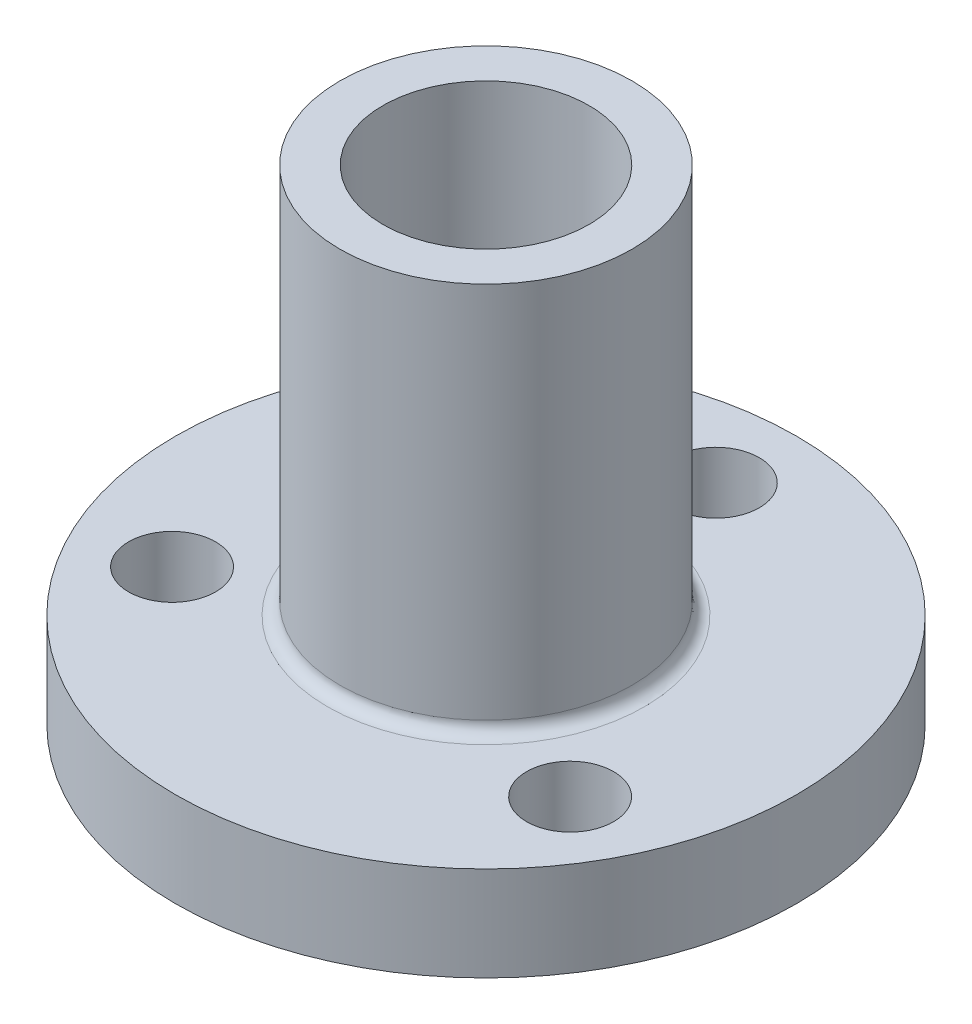
from build123d import *

# Parameters (mm, degrees)
ESBO_O1_R                = 12.5
ESBO_O1_R_2              = 1.75
ESBO_O1_R_3              = 5.875
RESSALTO_EXTRUS_O1_DEPTH = 3.8
ESBO_O1_3_R              = 5.875
ESBO_O1_3_R_2            = 4.15
RESSALTO_EXTRUS_O2_DEPTH = 19.5
FILETE1_R                = 0.5


with BuildPart() as part:
    # Esboço1 → Ressalto-extrusão1 (new body)
    with BuildSketch(Plane(origin=(0, 0, 0), x_dir=(1, 0, 0), z_dir=(0, 1, 0))):
        Circle(ESBO_O1_R)
        with Locations((-8.010734985, -4.625)):
            Circle(ESBO_O1_R_2, mode=Mode.SUBTRACT)
        with Locations((8.010734985, -4.625)):
            Circle(ESBO_O1_R_2, mode=Mode.SUBTRACT)
        Circle(ESBO_O1_R_3, mode=Mode.SUBTRACT)
        with Locations((0, 9.25)):
            Circle(ESBO_O1_R_2, mode=Mode.SUBTRACT)
    extrude(amount=RESSALTO_EXTRUS_O1_DEPTH)

    # Esboço1<3> → Ressalto-extrusão2 (add)
    with BuildSketch(Plane(origin=(0, 0, 0), x_dir=(1, 0, 0), z_dir=(0, 1, 0))):
        Circle(ESBO_O1_3_R)
        Circle(ESBO_O1_3_R_2, mode=Mode.SUBTRACT)
    extrude(amount=RESSALTO_EXTRUS_O2_DEPTH)

    # Filete1
    filete1_edges = [part.edges().sort_by_distance(p)[0] for p in [
        (-5.875, 3.8, 0),
    ]]
    fillet(filete1_edges, radius=FILETE1_R)


solid = part.part
